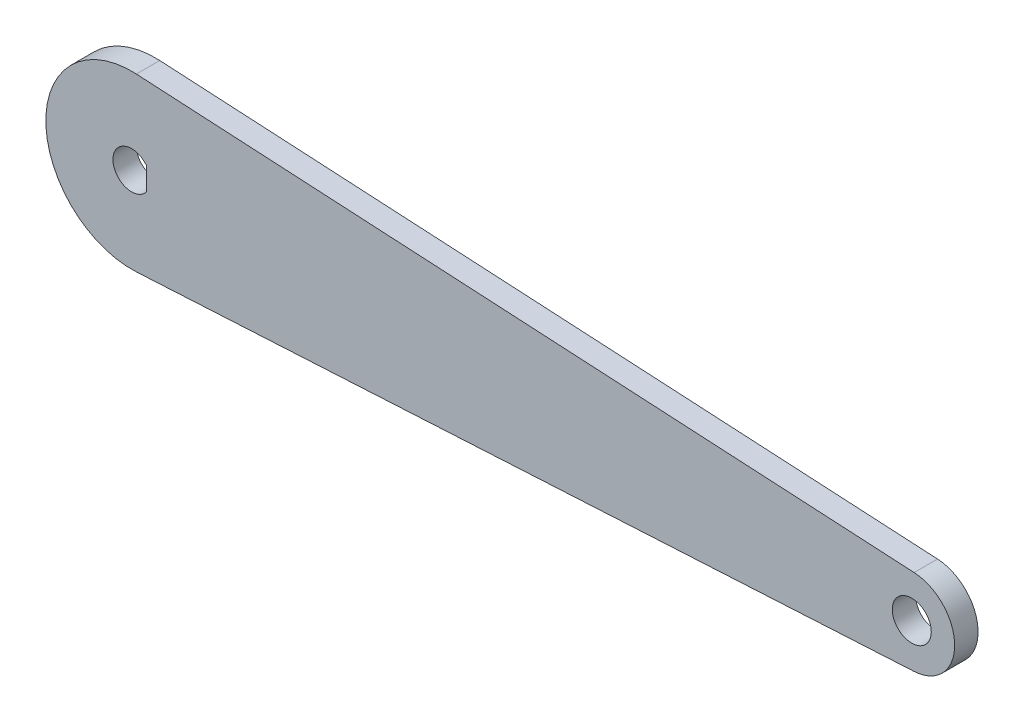
from build123d import *

# Parameters (mm, degrees)
SKETCH1_R           = 2.5
BOSS_EXTRUDE1_DEPTH = 3
CUT_EXTRUDE1_DEPTH  = 4


with BuildPart() as part:
    # Sketch1 → Boss-Extrude1 (new body)
    with BuildSketch(Plane.XY):
        with BuildLine():
            Line((0.605, 10.983349899), (100.3025, 5.491674949))
            ThreePointArc((100.3025, 5.491674949), (105.5, 0), (100.3025, -5.491674949))
            Line((100.3025, -5.491674949), (0.605, -10.983349899))
            ThreePointArc((0.605, -10.983349899), (-11, 0), (0.605, 10.983349899))
        make_face()
        with Locations((100, 0)):
            Circle(SKETCH1_R, mode=Mode.SUBTRACT)
    extrude(amount=BOSS_EXTRUDE1_DEPTH)

    # Sketch2 → Cut-Extrude1 (cut, through all)
    with BuildSketch(Plane.XY.offset(3)):
        with BuildLine():
            Line((1.9, 1.46628783), (1.9, -1.46628783))
            ThreePointArc((1.9, -1.46628783), (-2.4, 0), (1.9, 1.46628783))
        make_face()
    extrude(amount=-CUT_EXTRUDE1_DEPTH, mode=Mode.SUBTRACT)


solid = part.part
